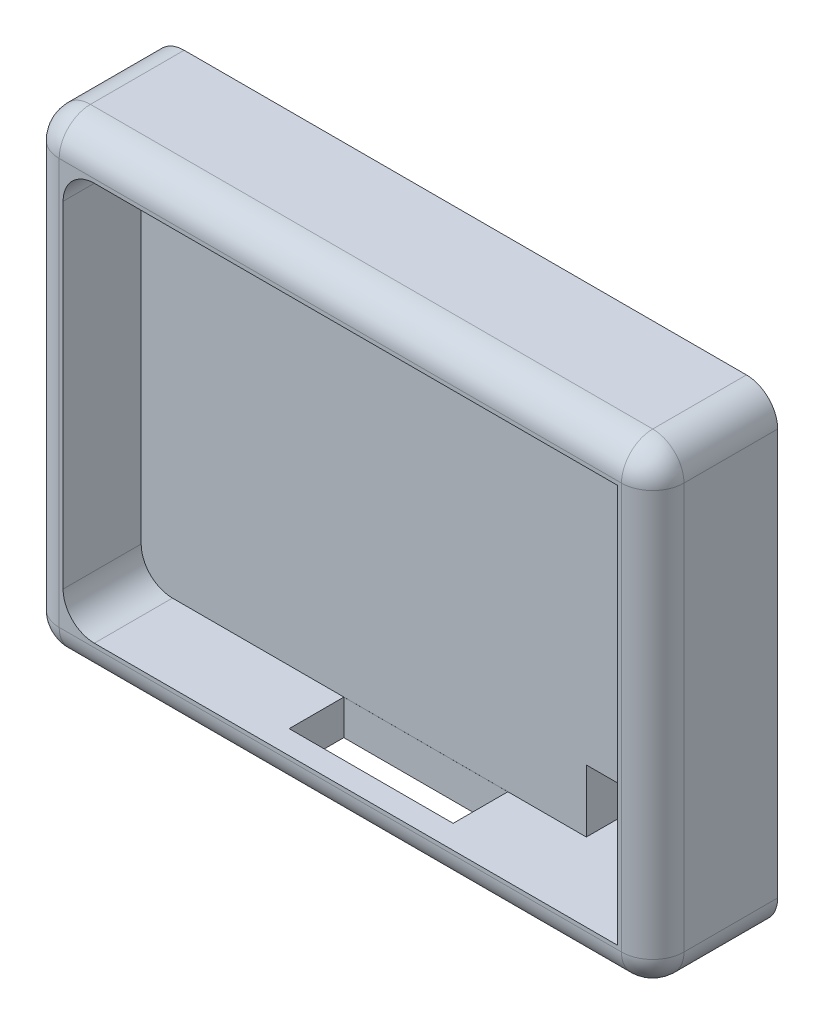
from build123d import *

# Parameters (mm, degrees)
SKETCH1_W           = 40
SKETCH1_H           = 30
BOSS_EXTRUDE1_DEPTH = 8
SKETCH2_W           = 35.5
SKETCH2_H           = 25.5
CUT_EXTRUDE1_DEPTH  = 5
FILLET1_R           = 2
FILLET2_R           = 2
SKETCH3_W           = 7
SKETCH3_H           = 4
CUT_EXTRUDE2_DEPTH  = 3
SKETCH6_W           = 10.5
SKETCH6_H           = 3.5
CUT_EXTRUDE3_DEPTH  = 2.25


with BuildPart() as part:
    # Sketch1 → Boss-Extrude1 (new body)
    with BuildSketch(Plane.XY):
        with Locations((20, 15)):
            Rectangle(SKETCH1_W, SKETCH1_H)
    extrude(amount=BOSS_EXTRUDE1_DEPTH)

    # Sketch2 → Cut-Extrude1 (cut)
    with BuildSketch(Plane.XY.offset(8)):
        with Locations((20, 15)):
            Rectangle(SKETCH2_W, SKETCH2_H)
    extrude(amount=-CUT_EXTRUDE1_DEPTH, mode=Mode.SUBTRACT)

    # Fillet1
    fillet1_edges = [part.edges().sort_by_distance(p)[0] for p in [
        (2.25, 2.25, 5.5),
        (2.25, 27.75, 5.5),
    ]]
    fillet(fillet1_edges, radius=FILLET1_R)

    # Fillet2
    fillet2_edges = [part.edges().sort_by_distance(p)[0] for p in [
        (40, 15, 8),
        (20, 30, 8),
        (0, 15, 8),
        (20, 0, 8),
        (0, 30, 4),
        (40, 30, 4),
        (40, 0, 4),
        (0, 0, 4),
    ]]
    fillet(fillet2_edges, radius=FILLET2_R)

    # Sketch3 → Cut-Extrude2 (cut)
    with BuildSketch(Plane.XY.offset(3)):
        with Locations((34.25, 4.25)):
            Rectangle(SKETCH3_W, SKETCH3_H)
    extrude(amount=-CUT_EXTRUDE2_DEPTH, mode=Mode.SUBTRACT)

    # Sketch6 → Cut-Extrude3 (cut)
    with BuildSketch(Plane(origin=(0, 2.25, 0), x_dir=(1, 0, 0), z_dir=(0, 1, 0))):
        with Locations((20.475771031, -4.752425865)):
            Rectangle(SKETCH6_W, SKETCH6_H)
    extrude(amount=-CUT_EXTRUDE3_DEPTH, mode=Mode.SUBTRACT)


solid = part.part
